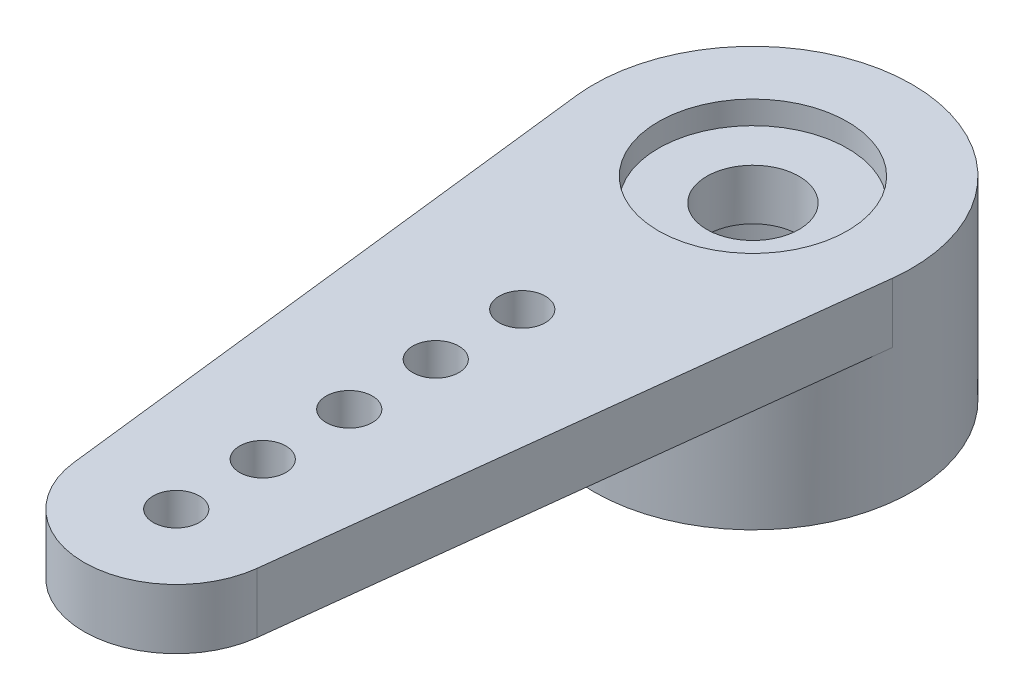
from build123d import *

# Parameters (mm, degrees)
SKETCH1_R           = 3.45
BOSS_EXTRUDE1_DEPTH = 4.2
BOSS_EXTRUDE2_DEPTH = 1.3
SKETCH2_R           = 2.05
CUT_EXTRUDE1_DEPTH  = 0.5
SKETCH4_R           = 0.5
CUT_EXTRUDE2_DEPTH  = 5.2
SKETCH5_R           = 1
CUT_EXTRUDE3_DEPTH  = 4.7
SKETCH6_R           = 2.5
CUT_EXTRUDE4_DEPTH  = 2.6


with BuildPart() as part:
    # Sketch1 → Boss-Extrude1 (new body)
    with BuildSketch(Plane(origin=(0, 0, 0), x_dir=(1, 0, 0), z_dir=(0, 1, 0))):
        Circle(SKETCH1_R)
    extrude(amount=BOSS_EXTRUDE1_DEPTH)

    # Sketch3 → Boss-Extrude2 (add)
    with BuildSketch(Plane(origin=(0, 4.2, 0), x_dir=(1, 0, 0), z_dir=(0, 1, 0))):
        with BuildLine():
            Line((-3.426709786, -0.4002), (-1.986498427, -12.732))
            ThreePointArc((-1.986498427, -12.732), (0, -14.5), (1.986498427, -12.732))
            Line((1.986498427, -12.732), (3.426709786, -0.4002))
            ThreePointArc((3.426709786, -0.4002), (0, 3.45), (-3.426709786, -0.4002))
        make_face()
    extrude(amount=-BOSS_EXTRUDE2_DEPTH)

    # Sketch2 → Cut-Extrude1 (cut)
    with BuildSketch(Plane(origin=(0, 4.2, 0), x_dir=(1, 0, 0), z_dir=(0, 1, 0))):
        Circle(SKETCH2_R)
    extrude(amount=-CUT_EXTRUDE1_DEPTH, mode=Mode.SUBTRACT)

    # Sketch4 → Cut-Extrude2 (cut, through all)
    with BuildSketch(Plane(origin=(0, 4.2, 0), x_dir=(1, 0, 0), z_dir=(0, 1, 0))):
        with Locations((0, -12.5)):
            Circle(SKETCH4_R)
        with Locations((0, -10.625)):
            Circle(SKETCH4_R)
        with Locations((0, -8.75)):
            Circle(SKETCH4_R)
        with Locations((0, -6.875)):
            Circle(SKETCH4_R)
        with Locations((0, -5)):
            Circle(SKETCH4_R)
    extrude(amount=-CUT_EXTRUDE2_DEPTH, mode=Mode.SUBTRACT)

    # Sketch5 → Cut-Extrude3 (cut, through all)
    with BuildSketch(Plane(origin=(0, 3.7, 0), x_dir=(1, 0, 0), z_dir=(0, 1, 0))):
        Circle(SKETCH5_R)
    extrude(amount=-CUT_EXTRUDE3_DEPTH, mode=Mode.SUBTRACT)

    # Sketch6 → Cut-Extrude4 (cut)
    with BuildSketch(Plane.XZ):
        Circle(SKETCH6_R)
    extrude(amount=-CUT_EXTRUDE4_DEPTH, mode=Mode.SUBTRACT)


solid = part.part
